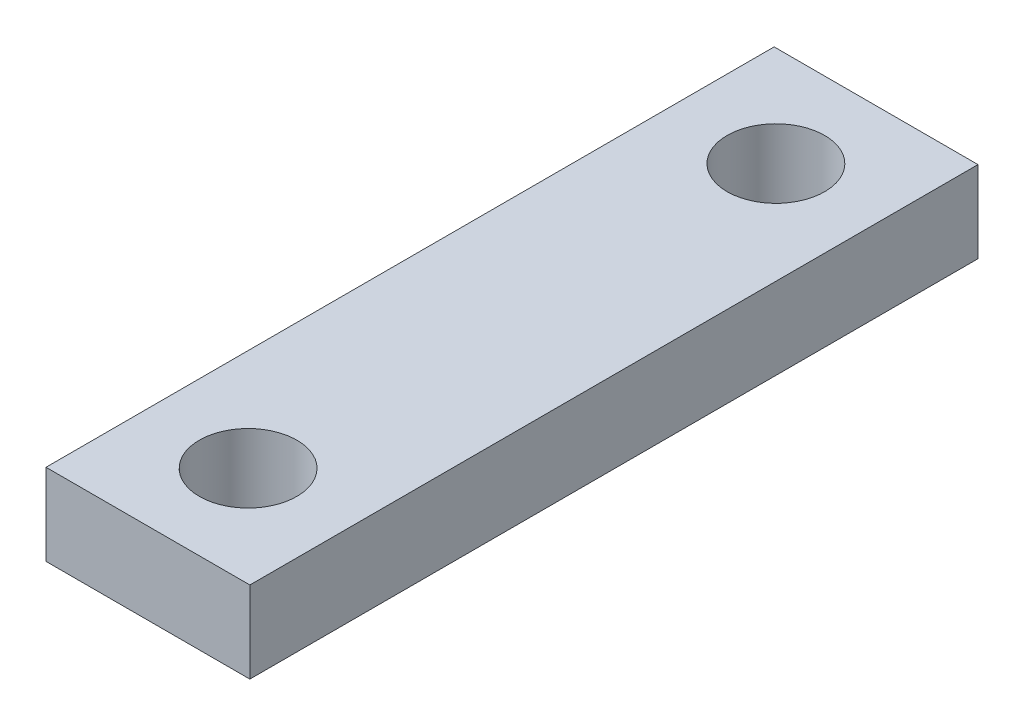
from build123d import *

# Parameters (mm, degrees)
SKETCH1_W           = 7.9375
SKETCH1_H           = 3.175
BOSS_EXTRUDE2_DEPTH = 28.35
SKETCH3_R           = 1.89865
CUT_EXTRUDE1_DEPTH  = 4.175


with BuildPart() as part:
    # Sketch1 → Boss-Extrude2 (new body)
    with BuildSketch(Plane.XY):
        with Locations((3.96875, 1.5875)):
            Rectangle(SKETCH1_W, SKETCH1_H)
    extrude(amount=BOSS_EXTRUDE2_DEPTH)

    # Sketch3 → Cut-Extrude1 (cut, through all)
    with BuildSketch(Plane(origin=(0, 3.175, 0), x_dir=(1, 0, 0), z_dir=(0, 1, 0))):
        with Locations((3.96875, -3.9)):
            Circle(SKETCH3_R)
        with Locations((3.96875, -24.45)):
            Circle(SKETCH3_R)
    extrude(amount=-CUT_EXTRUDE1_DEPTH, mode=Mode.SUBTRACT)


solid = part.part
